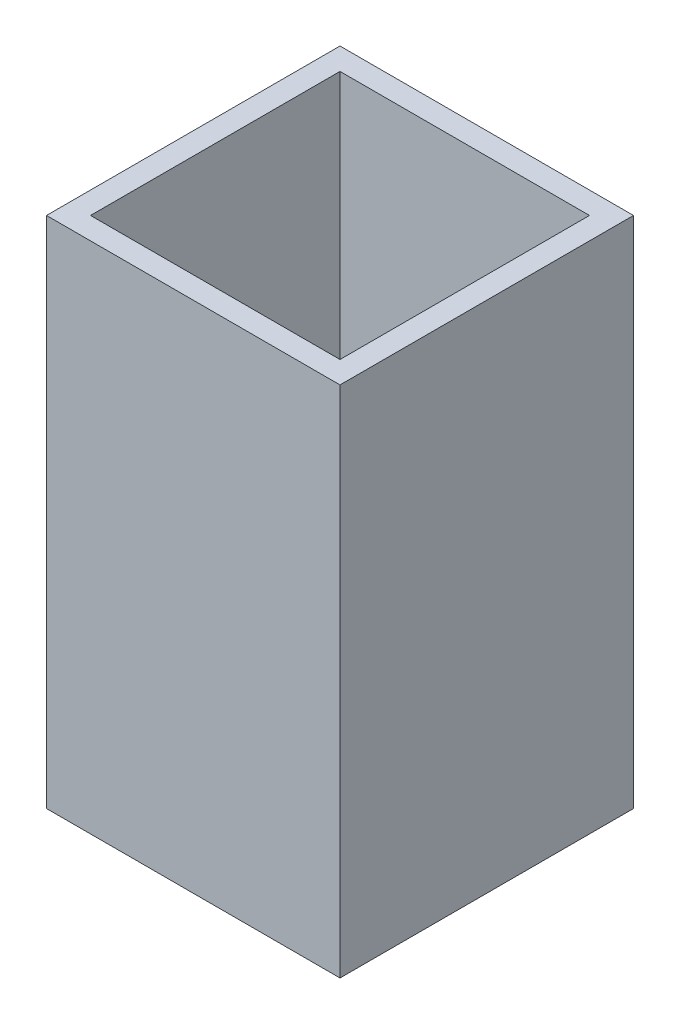
from build123d import *

# Parameters (mm, degrees)
SKETCH1_W           = 20
SKETCH1_H           = 20
SKETCH1_W_2         = 17
SKETCH1_H_2         = 17
BOSS_EXTRUDE1_DEPTH = 35


with BuildPart() as part:
    # Sketch1 → Boss-Extrude1 (new body)
    with BuildSketch(Plane(origin=(0, 0, 0), x_dir=(1, 0, 0), z_dir=(0, 1, 0))):
        Rectangle(SKETCH1_W, SKETCH1_H)
        Rectangle(SKETCH1_W_2, SKETCH1_H_2, mode=Mode.SUBTRACT)
    extrude(amount=BOSS_EXTRUDE1_DEPTH)


solid = part.part
